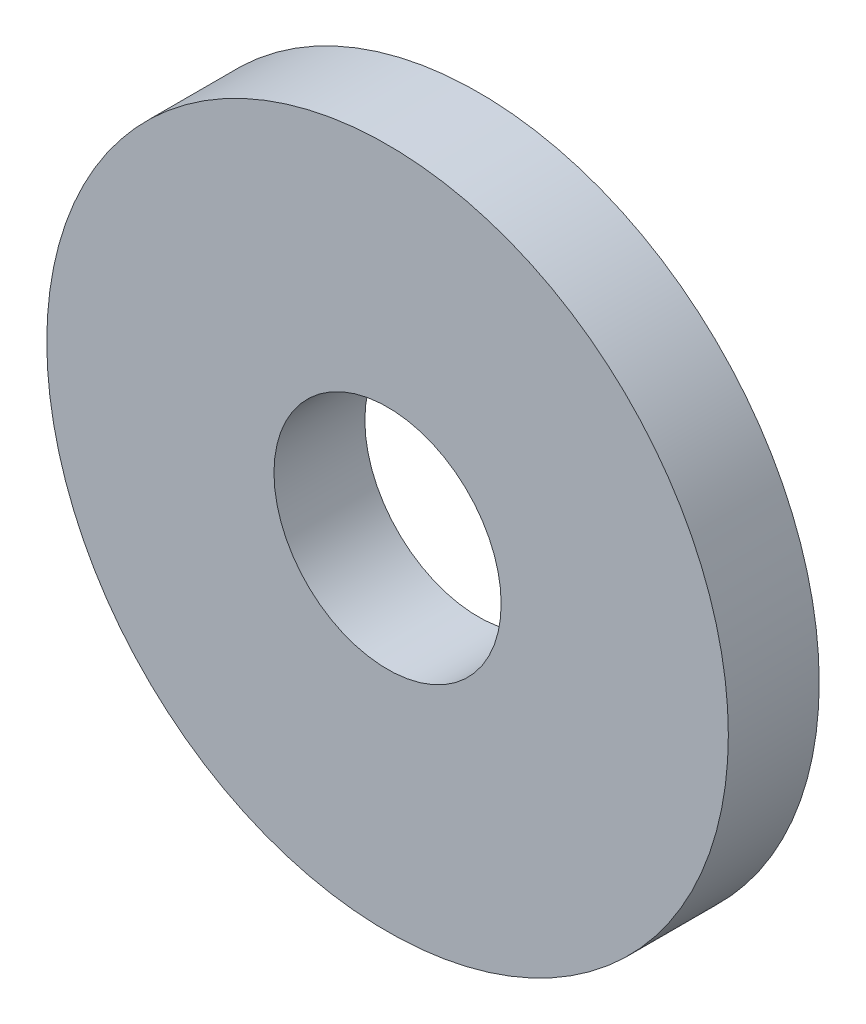
from build123d import *

# Parameters (mm, degrees)
ESQUISSE1_R      = 4.5
ESQUISSE1_R_2    = 1.5
EXTRUSION1_DEPTH = 1.2


with BuildPart() as part:
    # Esquisse1 → Extrusion1 (new body)
    with BuildSketch(Plane.XY):
        Circle(ESQUISSE1_R)
        Circle(ESQUISSE1_R_2, mode=Mode.SUBTRACT)
    extrude(amount=EXTRUSION1_DEPTH)


solid = part.part
